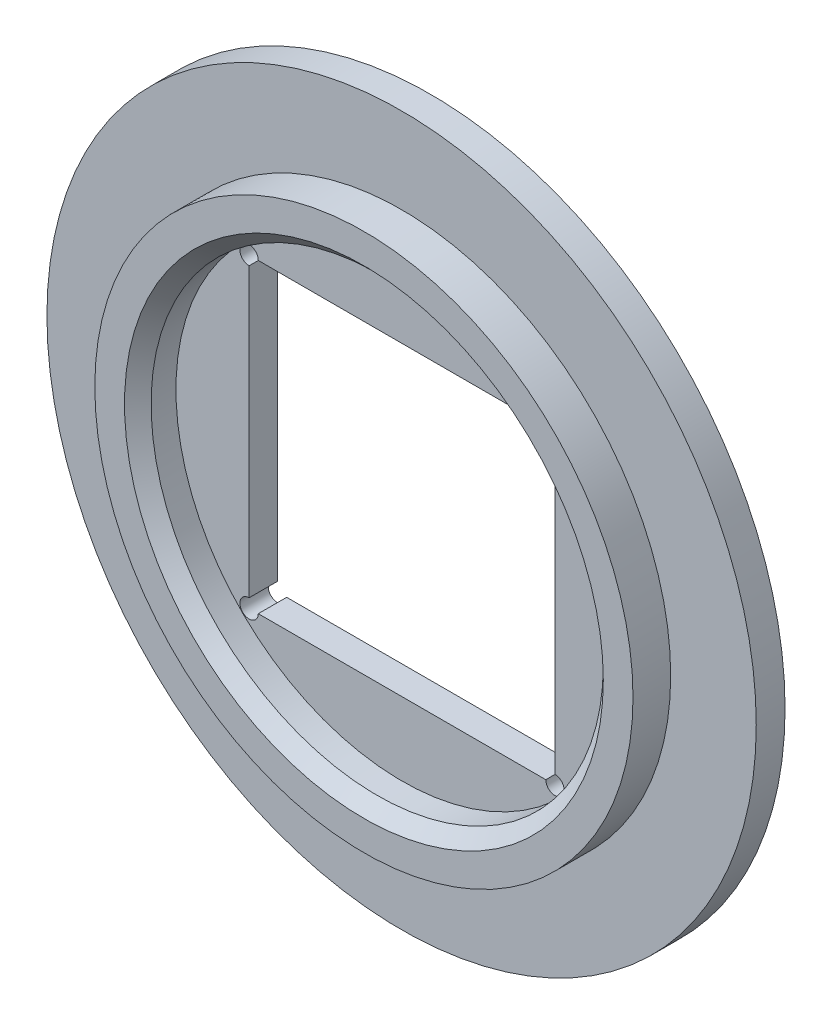
from build123d import *

# Parameters (mm, degrees)
SKETCH_1_R          = 8
EXTRUDE_1_DEPTH     = 0.65
EXTRUDE_START       = 0.65
SKETCH_2_R          = 6.07
SKETCH_2_R_2        = 5.1
EXTRUDE_2_DEPTH     = 0.85
CUT_EXTRUDE_START   = 0.65
SKETCH_3_R          = 5.1
CUT_EXTRUDE_1_DEPTH = 0.01
SKETCH_4_W          = 6.9
SKETCH_4_H          = 6.9
CUT_EXTRUDE_2_DEPTH = 0.64
CHAMFER_1_SIZE      = 0.3
SKETCH_6_R          = 0.207363545
CUT_EXTRUDE_3_DEPTH = 0.64


with BuildPart() as part:
    # 草图1 → 凸台-拉伸1 (new body)
    with BuildSketch(Plane.XY):
        Circle(SKETCH_1_R)
    extrude(amount=EXTRUDE_1_DEPTH)

    # 草图2 → 凸台-拉伸2 (add)
    with BuildSketch(Plane.XY.offset(EXTRUDE_START)):
        Circle(SKETCH_2_R)
        Circle(SKETCH_2_R_2, mode=Mode.SUBTRACT)
    extrude(amount=EXTRUDE_2_DEPTH)

    # 草图3 → 切除-拉伸1 (cut)
    with BuildSketch(Plane.XY.offset(CUT_EXTRUDE_START)):
        Circle(SKETCH_3_R)
    extrude(amount=-CUT_EXTRUDE_1_DEPTH, mode=Mode.SUBTRACT)

    # 草图4 → 切除-拉伸2 (cut)
    with BuildSketch(Plane.XY):
        Rectangle(SKETCH_4_W, SKETCH_4_H)
    extrude(amount=CUT_EXTRUDE_2_DEPTH, mode=Mode.SUBTRACT)

    # 倒角1
    chamfer_1_edges = [part.edges().sort_by_distance(p)[0] for p in [
        (-5.1, 0, 1.5),
    ]]
    chamfer(chamfer_1_edges, length=CHAMFER_1_SIZE)

    # 草图6 → 切除-拉伸3 (cut)
    with BuildSketch(Plane.XY):
        with Locations((-3.45, 3.45)):
            Circle(SKETCH_6_R)
        with Locations((3.45, 3.45)):
            Circle(SKETCH_6_R)
        with Locations((3.45, -3.45)):
            Circle(SKETCH_6_R)
        with Locations((-3.45, -3.45)):
            Circle(SKETCH_6_R)
    extrude(amount=CUT_EXTRUDE_3_DEPTH, mode=Mode.SUBTRACT)


solid = part.part
